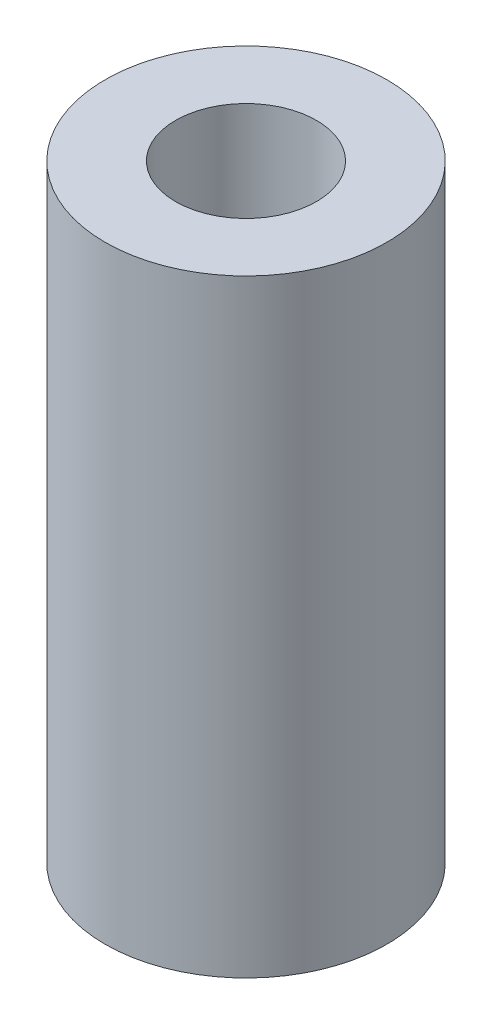
from build123d import *

# Parameters (mm, degrees)
SKETCH1_R           = 3
SKETCH1_R_2         = 1.5
BOSS_EXTRUDE1_DEPTH = 6.474


with BuildPart() as part:
    # Sketch1 → Boss-Extrude1 (new body, symmetric)
    with BuildSketch(Plane(origin=(0, 0, 0), x_dir=(1, 0, 0), z_dir=(0, 1, 0))):
        Circle(SKETCH1_R)
        Circle(SKETCH1_R_2, mode=Mode.SUBTRACT)
    extrude(amount=BOSS_EXTRUDE1_DEPTH, both=True)


solid = part.part
